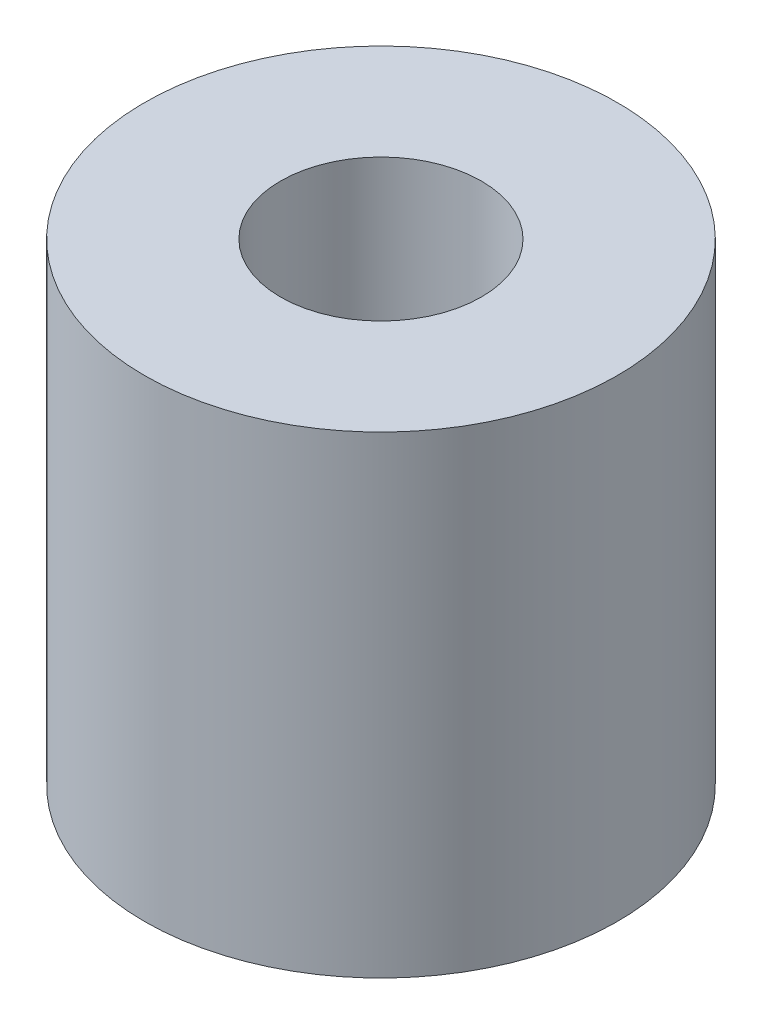
from build123d import *

# Parameters (mm, degrees)
SKETCH1_R           = 5
SKETCH1_R_2         = 2.125
BOSS_EXTRUDE1_DEPTH = 10


with BuildPart() as part:
    # Sketch1 → Boss-Extrude1 (new body)
    with BuildSketch(Plane(origin=(0, 0, 0), x_dir=(1, 0, 0), z_dir=(0, 1, 0))):
        Circle(SKETCH1_R)
        Circle(SKETCH1_R_2, mode=Mode.SUBTRACT)
    extrude(amount=BOSS_EXTRUDE1_DEPTH)


solid = part.part
